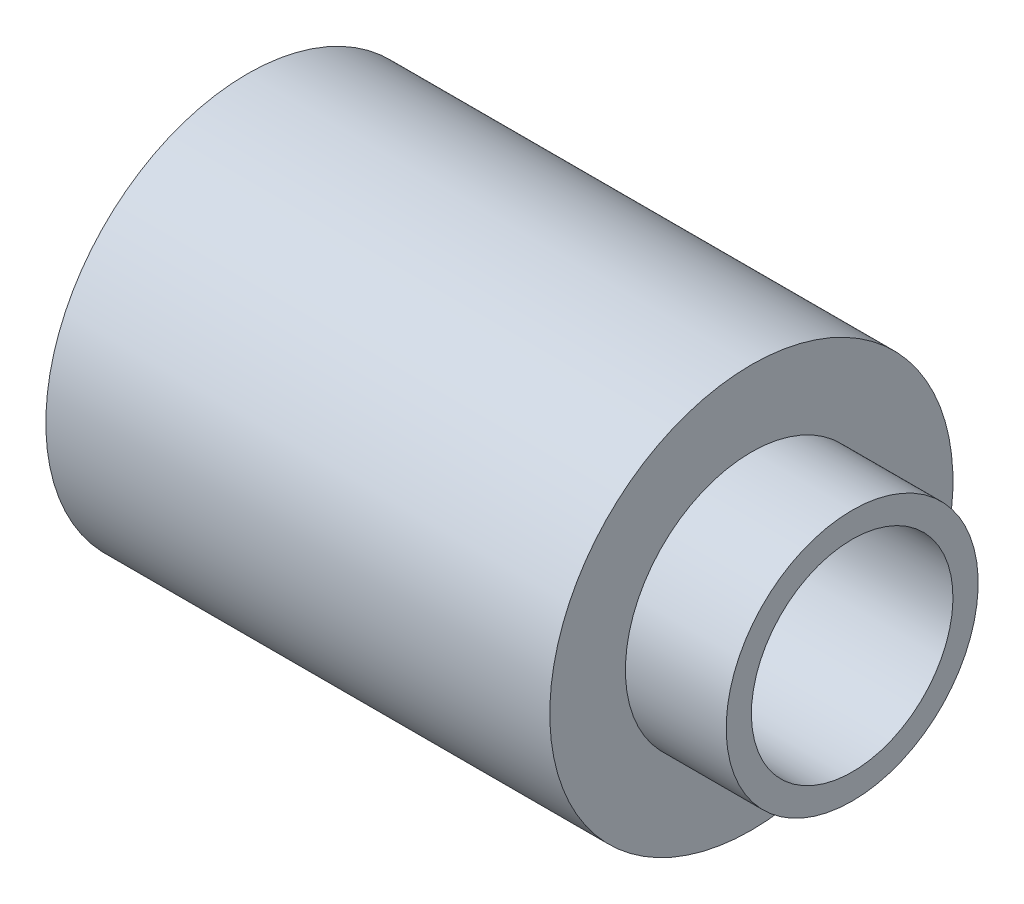
from build123d import *

# Parameters (mm, degrees)
SKETCH3_R          = 2
CUT_EXTRUDE1_DEPTH = 13


with BuildPart() as part:
    # Sketch2 → Revolve1 (revolve)
    with BuildSketch(Plane.XY):
        Polygon((0, 0), (-12, 0), (-12, 4), (-2, 4), (-2, 2.5), (0, 2.5), align=None)
    revolve(axis=Axis((0, 0, 0), (-1, 0, 0)))

    # Sketch3 → Cut-Extrude1 (cut, through all)
    with BuildSketch(Plane(origin=(0, 0, 0), x_dir=(0, 0, -1), z_dir=(1, 0, 0))):
        Circle(SKETCH3_R)
    extrude(amount=-CUT_EXTRUDE1_DEPTH, mode=Mode.SUBTRACT)


solid = part.part
